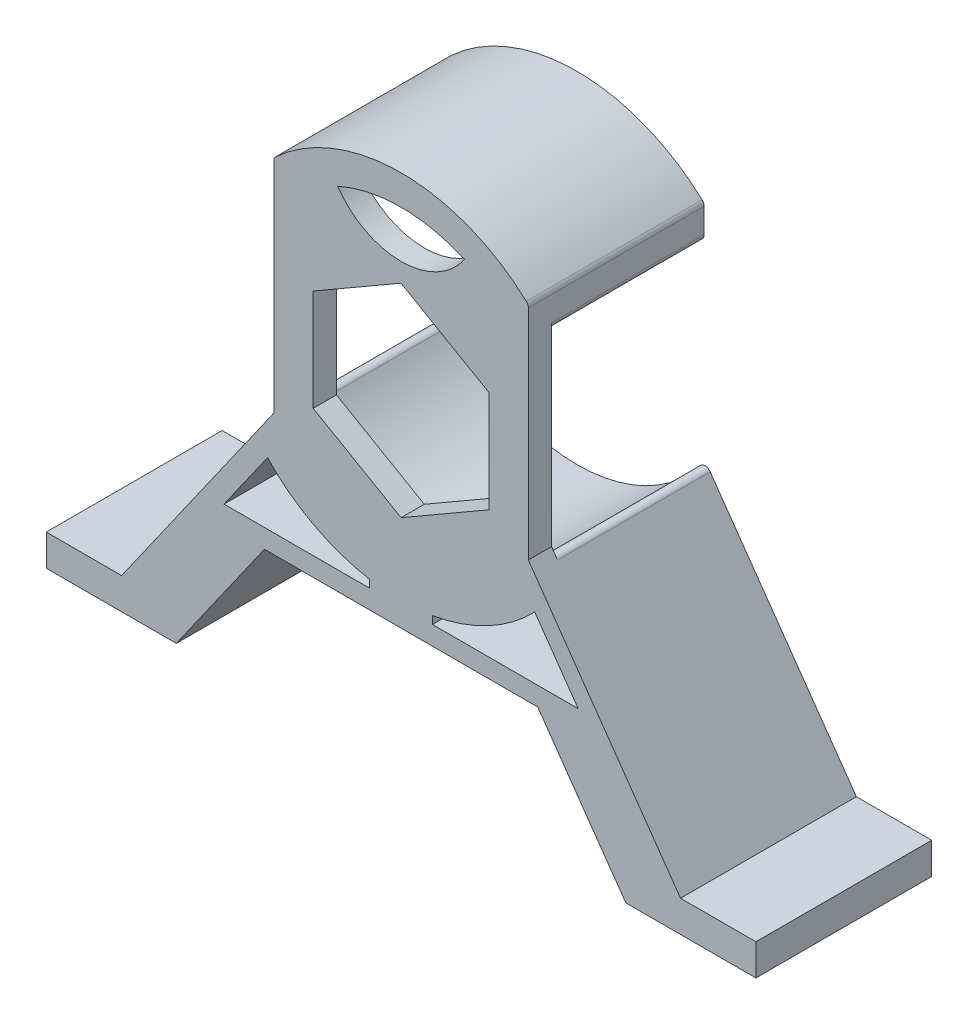
from build123d import *

# Parameters (mm, degrees)
BOSS_EXTRU_1_DEPTH      = 28
ESQUISSE2_R             = 24.75
ENL_V_MAT_EXTRU_1_DEPTH = 24.3
ENL_V_MAT_EXTRU_6_DEPTH = 29
CONG_1_R                = 1


with BuildPart() as part:
    # Esquisse1 → Boss.-Extru.1 (new body)
    with BuildSketch(Plane.XY):
        with BuildLine():
            Line((-56.5, 0), (-56.5, 5))
            Line((-56.5, 5), (-44.5, 5))
            Line((-44.5, 5), (-20.262248583, 39.527154166))
            Line((-20.262248583, 39.527154166), (-20.262248583, 74.740412365))
            ThreePointArc((-20.262248583, 74.740412365), (0, 82.8), (20.262248583, 74.740412365))
            Line((20.262248583, 74.740412365), (20.262248583, 39.527154166))
            Line((20.262248583, 39.527154166), (44.5, 5))
            Line((44.5, 5), (56.5, 5))
            Line((56.5, 5), (56.5, 0))
            Line((56.5, 0), (35.791970863, 0))
            Line((35.791970863, 0), (21.7521509, 20))
            Line((21.7521509, 20), (-21.7521509, 20))
            Line((-21.7521509, 20), (-35.791970863, 0))
            Line((-35.791970863, 0), (-56.5, 0))
        make_face()
    extrude(amount=BOSS_EXTRU_1_DEPTH)

    # Esquisse2 → Enlèv. mat.-Extru.1 (cut)
    with BuildSketch(Plane.XY):
        with Locations((0, 53.3)):
            Circle(ESQUISSE2_R)
    extrude(amount=ENL_V_MAT_EXTRU_1_DEPTH, mode=Mode.SUBTRACT)

    # Esquisse5 → Enlèv. mat.-Extru.6 (cut, through all)
    with BuildSketch(Plane.XY.offset(28)):
        Polygon((0, 67.565807537), (-14, 59.482903769), (-14, 43.317096231), (0, 35.234192463), (14, 43.317096231), (14, 59.482903769), align=None)
        with BuildLine():
            Line((-21.274554731, 32.863676431), (-28.198766795, 23))
            Line((-28.198766795, 23), (-5, 23))
            Line((-5, 23), (-5, 24.22681648))
            ThreePointArc((-5, 24.22681648), (-13.828842831, 27.242120079), (-21.274554731, 32.863676431))
        make_face()
        with BuildLine():
            Line((21.274554731, 32.863676431), (28.198766795, 23))
            Line((28.198766795, 23), (5, 23))
            Line((5, 23), (5, 24.22681648))
            ThreePointArc((5, 24.22681648), (13.828842831, 27.242120079), (21.274554731, 32.863676431))
        make_face()
        with BuildLine():
            ThreePointArc((-10.099699908, 75.895542962), (0, 70.565807537), (10.099699908, 75.895542962))
            ThreePointArc((10.099699908, 75.895542962), (0, 78.05), (-10.099699908, 75.895542962))
        make_face()
    extrude(amount=-ENL_V_MAT_EXTRU_6_DEPTH, mode=Mode.SUBTRACT)

    # Congé1
    cong_1_edges = [part.edges().sort_by_distance(p)[0] for p in [
        (-20.262248583, 74.740412365, 14),
        (20.262248583, 74.740412365, 14),
        (20.415715975, 39.308536844, 12.15),
        (20.262248583, 67.512803466, 12.15),
        (-20.262248583, 67.512803466, 12.15),
        (-20.415715975, 39.308536844, 12.15),
    ]]
    fillet(cong_1_edges, radius=CONG_1_R)


solid = part.part
